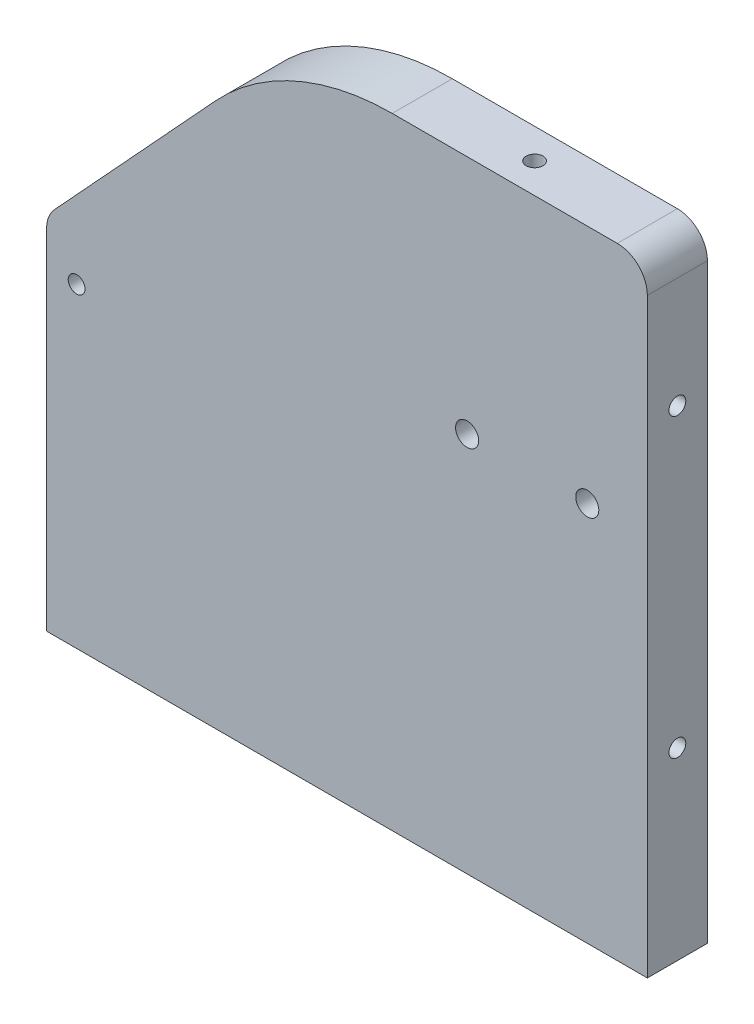
from build123d import *

# Parameters (mm, degrees)
BOSS_EXTRUDE1_DEPTH       = 3.175
FILLET1_R                 = 25.4
FILLET2_R                 = 3.175
FILLET3_R                 = 3.175
F_2_56_TAPPED_HOLE1_D     = 1.778
F_2_56_TAPPED_HOLE1_DEPTH = 5.588
F_2_56_TAPPED_HOLE1_TIP   = 0.53416509
F_2_CLEARANCE_HOLE1_D     = 2.4384
F_2_CLEARANCE_HOLE1_DEPTH = 25.4
F_2_CLEARANCE_HOLE1_TIP   = 0.732569267
SKETCH12_W                = 1.5875
SKETCH12_H                = 3.175
CUT_EXTRUDE1_DEPTH        = 3.175
F_2_56_TAPPED_HOLE2_D     = 1.778
F_2_56_TAPPED_HOLE2_DEPTH = 5.588
F_2_56_TAPPED_HOLE2_TIP   = 0.53416509
F_2_56_TAPPED_HOLE3_D     = 1.778
F_2_56_TAPPED_HOLE3_DEPTH = 5.588
F_2_56_TAPPED_HOLE3_TIP   = 0.53416509
F_2_56_TAPPED_HOLE4_D     = 1.778
F_2_56_TAPPED_HOLE4_DEPTH = 10.668
F_2_56_TAPPED_HOLE4_TIP   = 0.53416509


with BuildPart() as part:
    # Sketch1 → Boss-Extrude1 (new body, symmetric)
    with BuildSketch(Plane.XY):
        Polygon((0, 38.1), (0, 0), (63.5, 0), (63.5, 65.659), (25.4, 65.659), align=None)
    extrude(amount=BOSS_EXTRUDE1_DEPTH, both=True)

    # Fillet1
    fillet1_edges = [part.edges().sort_by_distance(p)[0] for p in [
        (25.4, 65.659, 0),
    ]]
    fillet(fillet1_edges, radius=FILLET1_R)

    # Fillet2
    fillet2_edges = [part.edges().sort_by_distance(p)[0] for p in [
        (0, 38.1, 0),
    ]]
    fillet(fillet2_edges, radius=FILLET2_R)

    # Fillet3
    fillet3_edges = [part.edges().sort_by_distance(p)[0] for p in [
        (63.5, 65.659, 0),
    ]]
    fillet(fillet3_edges, radius=FILLET3_R)

    # #2-56 Tapped Hole1
    with Locations(Plane(origin=(63.5, 0, 0), x_dir=(0, 0, -1), z_dir=(1, 0, 0))):
        with Locations((0, 50.796059009), (0, 19.476973799)):
            Hole(F_2_56_TAPPED_HOLE1_D / 2, depth=F_2_56_TAPPED_HOLE1_DEPTH)
            with Locations((0, 0, -(F_2_56_TAPPED_HOLE1_DEPTH + F_2_56_TAPPED_HOLE1_TIP / 2))):  # 118° drill point
                Cone(0, F_2_56_TAPPED_HOLE1_D / 2, F_2_56_TAPPED_HOLE1_TIP, mode=Mode.SUBTRACT)

    # #2 Clearance Hole1
    with Locations(Plane.XY.offset(3.175)):
        with Locations((57.15, 40.259), (44.45, 40.259)):
            Hole(F_2_CLEARANCE_HOLE1_D / 2, depth=F_2_CLEARANCE_HOLE1_DEPTH)
            with Locations((0, 0, -(F_2_CLEARANCE_HOLE1_DEPTH + F_2_CLEARANCE_HOLE1_TIP / 2))):  # 118° drill point
                Cone(0, F_2_CLEARANCE_HOLE1_D / 2, F_2_CLEARANCE_HOLE1_TIP, mode=Mode.SUBTRACT)

    # Sketch12 → Cut-Extrude1 (cut)
    with BuildSketch(Plane(origin=(0, 0, -3.175), x_dir=(-1, 0, 0), z_dir=(0, 0, -1))):
        with Locations((-2.38125, 23.8125)):
            Rectangle(SKETCH12_W, SKETCH12_H)
        with Locations((-2.38125, 11.1125)):
            Rectangle(SKETCH12_W, SKETCH12_H)
    extrude(amount=-CUT_EXTRUDE1_DEPTH, mode=Mode.SUBTRACT)

    # #2-56 Tapped Hole2
    with Locations(Plane(origin=(-18.986783635, 17.499339756, 0), x_dir=(0, 0, 1), z_dir=(-0.735322884, 0.677716944, 0))):
        with Locations((0, 41.828773603)):
            Hole(F_2_56_TAPPED_HOLE2_D / 2, depth=F_2_56_TAPPED_HOLE2_DEPTH)
            with Locations((0, 0, -(F_2_56_TAPPED_HOLE2_DEPTH + F_2_56_TAPPED_HOLE2_TIP / 2))):  # 118° drill point
                Cone(0, F_2_56_TAPPED_HOLE2_D / 2, F_2_56_TAPPED_HOLE2_TIP, mode=Mode.SUBTRACT)

    # #2-56 Tapped Hole3
    with Locations(Plane(origin=(0, 65.659, 0), x_dir=(-1, 0, 0), z_dir=(0, 1, 0))):
        with Locations((-48.407010359, 0)):
            Hole(F_2_56_TAPPED_HOLE3_D / 2, depth=F_2_56_TAPPED_HOLE3_DEPTH)
            with Locations((0, 0, -(F_2_56_TAPPED_HOLE3_DEPTH + F_2_56_TAPPED_HOLE3_TIP / 2))):  # 118° drill point
                Cone(0, F_2_56_TAPPED_HOLE3_D / 2, F_2_56_TAPPED_HOLE3_TIP, mode=Mode.SUBTRACT)

    # #2-56 Tapped Hole4
    with Locations(Plane.XY.offset(3.175)):
        with Locations((3.175, 33.3375)):
            Hole(F_2_56_TAPPED_HOLE4_D / 2, depth=F_2_56_TAPPED_HOLE4_DEPTH)
            with Locations((0, 0, -(F_2_56_TAPPED_HOLE4_DEPTH + F_2_56_TAPPED_HOLE4_TIP / 2))):  # 118° drill point
                Cone(0, F_2_56_TAPPED_HOLE4_D / 2, F_2_56_TAPPED_HOLE4_TIP, mode=Mode.SUBTRACT)


solid = part.part
